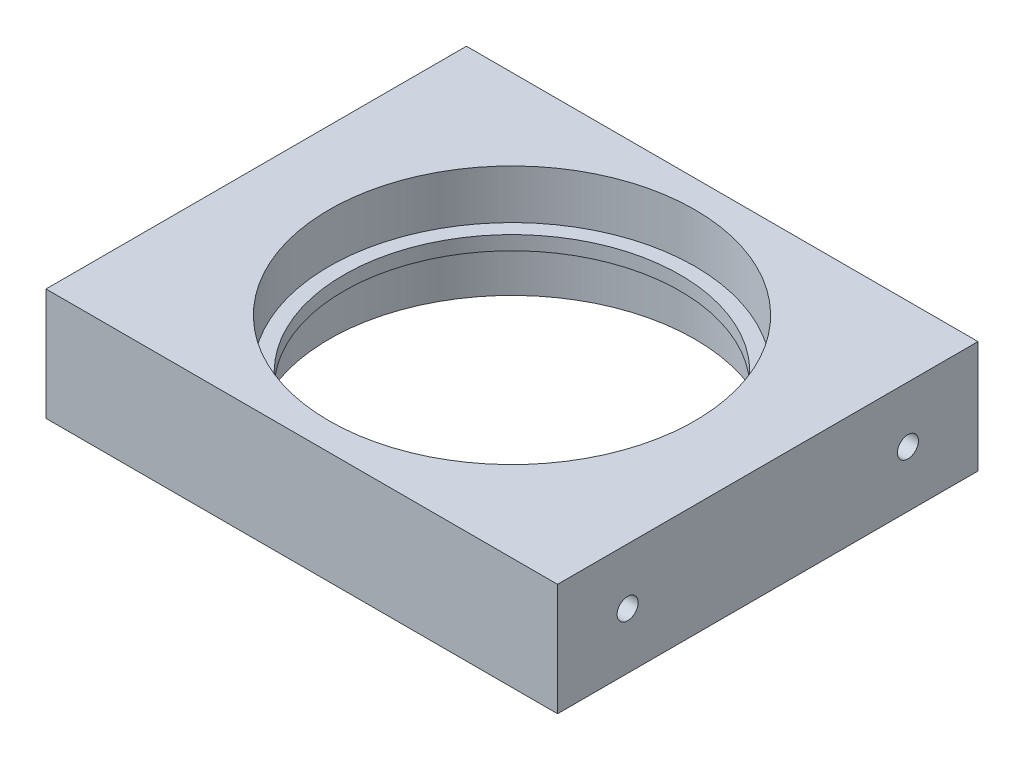
from build123d import *

# Parameters (mm, degrees)
SKETCH1_W           = 73
SKETCH1_H           = 60
SKETCH1_R           = 26.1
BOSS_EXTRUDE1_DEPTH = 16
BOSS_EXTRUDE2_START = -7
SKETCH3_R           = 26.1
SKETCH3_R_2         = 24
BOSS_EXTRUDE2_DEPTH = 2
SKETCH2_R           = 1.5
CUT_EXTRUDE1_DEPTH  = 15
CUT_EXTRUDE2_START  = -73
SKETCH2_2_R         = 1.5
CUT_EXTRUDE2_DEPTH  = 15


with BuildPart() as part:
    # Sketch1 → Boss-Extrude1 (new body)
    with BuildSketch(Plane(origin=(0, 0, 0), x_dir=(1, 0, 0), z_dir=(0, 1, 0))):
        with Locations((36.5, 30)):
            Rectangle(SKETCH1_W, SKETCH1_H)
        with Locations((36.5, 30)):
            Circle(SKETCH1_R, mode=Mode.SUBTRACT)
    extrude(amount=BOSS_EXTRUDE1_DEPTH)

    # Sketch3 → Boss-Extrude2 (add)
    with BuildSketch(Plane(origin=(0, 16, 0), x_dir=(1, 0, 0), z_dir=(0, 1, 0)).offset(BOSS_EXTRUDE2_START)):
        with Locations((36.5, 30)):
            Circle(SKETCH3_R)
        with Locations((36.5, 30)):
            Circle(SKETCH3_R_2, mode=Mode.SUBTRACT)
    extrude(amount=-BOSS_EXTRUDE2_DEPTH)

    # Sketch2 → Cut-Extrude1 (cut)
    with BuildSketch(Plane(origin=(73, 0, 0), x_dir=(0, 0, -1), z_dir=(1, 0, 0))):
        with Locations((10, 8)):
            Circle(SKETCH2_R)
        with Locations((50, 8)):
            Circle(SKETCH2_R)
    extrude(amount=-CUT_EXTRUDE1_DEPTH, mode=Mode.SUBTRACT)

    # Sketch2_2 → Cut-Extrude2 (cut)
    with BuildSketch(Plane(origin=(73, 0, 0), x_dir=(0, 0, -1), z_dir=(1, 0, 0)).offset(CUT_EXTRUDE2_START)):
        with Locations((10, 8)):
            Circle(SKETCH2_2_R)
        with Locations((50, 8)):
            Circle(SKETCH2_2_R)
    extrude(amount=CUT_EXTRUDE2_DEPTH, mode=Mode.SUBTRACT)


solid = part.part
